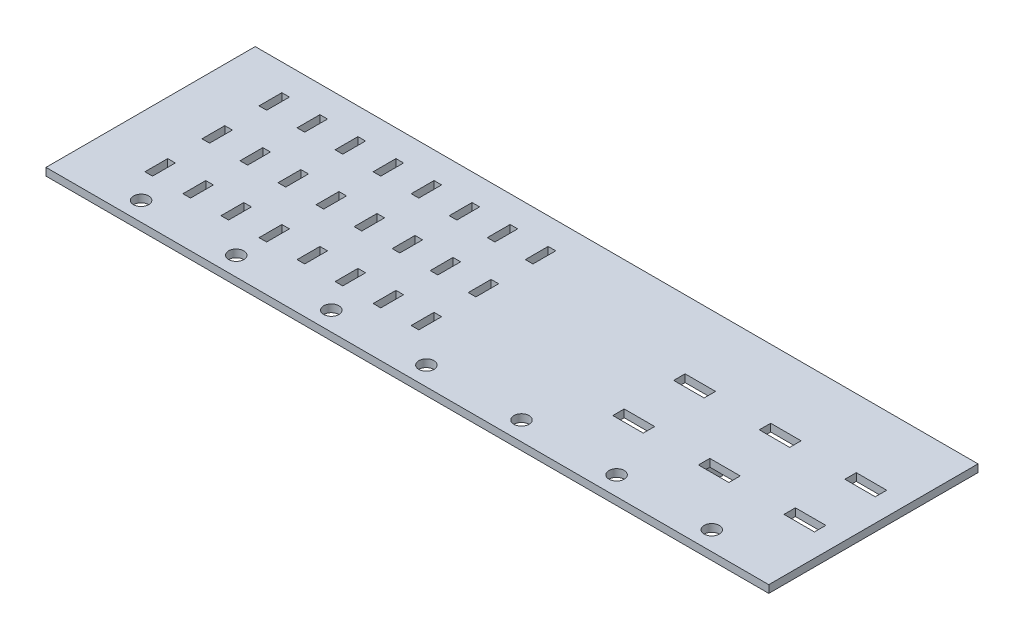
from build123d import *

# Parameters (mm, degrees)
SKETCH1_W                 = 190
SKETCH1_H                 = 55
SKETCH1_R                 = 2
BOSS_EXTRUDE1_DEPTH       = 2
SKETCH2_W                 = 10
SKETCH2_H                 = 10
BOSS_EXTRUDE2_DEPTH       = 7.1
LPATTERN1_COUNT           = 2
LPATTERN1_PITCH           = 22.5
SKETCH3_W                 = 8
SKETCH3_H                 = 3
CUT_EXTRUDE1_DEPTH        = 7.1
LPATTERN2_COUNT           = 3
LPATTERN2_PITCH           = 22.5
SKETCH4_W                 = 2
SKETCH4_H                 = 6
CUT_EXTRUDE2_DEPTH        = 7.1
LPATTERN3_COUNT           = 3
LPATTERN3_PITCH           = 15
LPATTERN4_COUNT           = 4
LPATTERN4_PITCH           = 20
LPATTERN4_COPY_1_SKETCH_W = 2
LPATTERN4_COPY_1_SKETCH_H = 6
LPATTERN4_COPY_1_DEPTH    = 7.1
LPATTERN4_COPY_2_SKETCH_W = 2
LPATTERN4_COPY_2_SKETCH_H = 6
LPATTERN4_COPY_2_DEPTH    = 7.1
LPATTERN4_COPY_3_SKETCH_W = 2
LPATTERN4_COPY_3_SKETCH_H = 6
LPATTERN4_COPY_3_DEPTH    = 7.1
LPATTERN4_COPY_4_SKETCH_W = 2
LPATTERN4_COPY_4_SKETCH_H = 6
LPATTERN4_COPY_4_DEPTH    = 7.1
LPATTERN4_COPY_5_SKETCH_W = 2
LPATTERN4_COPY_5_SKETCH_H = 6
LPATTERN4_COPY_5_DEPTH    = 7.1
LPATTERN4_COPY_6_SKETCH_W = 2
LPATTERN4_COPY_6_SKETCH_H = 6
LPATTERN4_COPY_6_DEPTH    = 7.1
SKETCH5_W                 = 10
SKETCH5_H                 = 10
BOSS_EXTRUDE3_DEPTH       = 7.1


with BuildPart() as part:
    # Sketch1 → Boss-Extrude1 (new body)
    with BuildSketch(Plane(origin=(0, 0, 0), x_dir=(1, 0, 0), z_dir=(0, 1, 0))):
        with Locations((75, 22.5)):
            Rectangle(SKETCH1_W, SKETCH1_H)
        Circle(SKETCH1_R, mode=Mode.SUBTRACT)
        with Locations((25, 0)):
            Circle(SKETCH1_R, mode=Mode.SUBTRACT)
        with Locations((50, 0)):
            Circle(SKETCH1_R, mode=Mode.SUBTRACT)
        with Locations((75, 0)):
            Circle(SKETCH1_R, mode=Mode.SUBTRACT)
        with Locations((100, 0)):
            Circle(SKETCH1_R, mode=Mode.SUBTRACT)
        with Locations((125, 0)):
            Circle(SKETCH1_R, mode=Mode.SUBTRACT)
        with Locations((150, 0)):
            Circle(SKETCH1_R, mode=Mode.SUBTRACT)
    extrude(amount=BOSS_EXTRUDE1_DEPTH)

    # Sketch2 → Boss-Extrude2 (add)
    with BuildSketch(Plane.XZ):
        with Locations((125, -22.5)):
            Rectangle(SKETCH2_W, SKETCH2_H)
    boss_extrude2 = extrude(amount=BOSS_EXTRUDE2_DEPTH)

    # LPattern1: Boss-Extrude2 ×2
    with Locations(*[(0, 0, -i * LPATTERN1_PITCH) for i in range(1, LPATTERN1_COUNT)]):
        add(boss_extrude2)

    # Sketch3 → Cut-Extrude1 (cut)
    with BuildSketch(Plane(origin=(0, 2, 0), x_dir=(1, 0, 0), z_dir=(0, 1, 0))):
        with Locations((160, 30.5)):
            Rectangle(SKETCH3_W, SKETCH3_H)
        with Locations((160, 14.5)):
            Rectangle(SKETCH3_W, SKETCH3_H)
    cut_extrude1 = extrude(amount=-CUT_EXTRUDE1_DEPTH, mode=Mode.SUBTRACT)

    # LPattern2: Cut-Extrude1 ×3
    with Locations(*[(-i * LPATTERN2_PITCH, 0, 0) for i in range(1, LPATTERN2_COUNT)]):
        add(cut_extrude1, mode=Mode.SUBTRACT)

    # Sketch4 → Cut-Extrude2 (cut)
    with BuildSketch(Plane(origin=(0, 2, 0), x_dir=(1, 0, 0), z_dir=(0, 1, 0))):
        with Locations((-5, 10)):
            Rectangle(SKETCH4_W, SKETCH4_H)
        with Locations((5, 10)):
            Rectangle(SKETCH4_W, SKETCH4_H)
    cut_extrude2 = extrude(amount=-CUT_EXTRUDE2_DEPTH, mode=Mode.SUBTRACT)

    # LPattern3: Cut-Extrude2 ×3
    with Locations(*[(0, 0, -i * LPATTERN3_PITCH) for i in range(1, LPATTERN3_COUNT)]):
        add(cut_extrude2, mode=Mode.SUBTRACT)

    # LPattern4: Cut-Extrude2 ×4
    with Locations(*[(i * LPATTERN4_PITCH, 0, 0) for i in range(1, LPATTERN4_COUNT)]):
        add(cut_extrude2, mode=Mode.SUBTRACT)

    # LPattern4 copy 1 sketch → LPattern4 copy 1 (cut)
    with BuildSketch(Plane(origin=(20, 2, -15), x_dir=(1, 0, 0), z_dir=(0, 1, 0))):
        with Locations((-5, 10)):
            Rectangle(LPATTERN4_COPY_1_SKETCH_W, LPATTERN4_COPY_1_SKETCH_H)
        with Locations((5, 10)):
            Rectangle(LPATTERN4_COPY_1_SKETCH_W, LPATTERN4_COPY_1_SKETCH_H)
    extrude(amount=-LPATTERN4_COPY_1_DEPTH, mode=Mode.SUBTRACT)

    # LPattern4 copy 2 sketch → LPattern4 copy 2 (cut)
    with BuildSketch(Plane(origin=(40, 2, -15), x_dir=(1, 0, 0), z_dir=(0, 1, 0))):
        with Locations((-5, 10)):
            Rectangle(LPATTERN4_COPY_2_SKETCH_W, LPATTERN4_COPY_2_SKETCH_H)
        with Locations((5, 10)):
            Rectangle(LPATTERN4_COPY_2_SKETCH_W, LPATTERN4_COPY_2_SKETCH_H)
    extrude(amount=-LPATTERN4_COPY_2_DEPTH, mode=Mode.SUBTRACT)

    # LPattern4 copy 3 sketch → LPattern4 copy 3 (cut)
    with BuildSketch(Plane(origin=(60, 2, -15), x_dir=(1, 0, 0), z_dir=(0, 1, 0))):
        with Locations((-5, 10)):
            Rectangle(LPATTERN4_COPY_3_SKETCH_W, LPATTERN4_COPY_3_SKETCH_H)
        with Locations((5, 10)):
            Rectangle(LPATTERN4_COPY_3_SKETCH_W, LPATTERN4_COPY_3_SKETCH_H)
    extrude(amount=-LPATTERN4_COPY_3_DEPTH, mode=Mode.SUBTRACT)

    # LPattern4 copy 4 sketch → LPattern4 copy 4 (cut)
    with BuildSketch(Plane(origin=(20, 2, -30), x_dir=(1, 0, 0), z_dir=(0, 1, 0))):
        with Locations((-5, 10)):
            Rectangle(LPATTERN4_COPY_4_SKETCH_W, LPATTERN4_COPY_4_SKETCH_H)
        with Locations((5, 10)):
            Rectangle(LPATTERN4_COPY_4_SKETCH_W, LPATTERN4_COPY_4_SKETCH_H)
    extrude(amount=-LPATTERN4_COPY_4_DEPTH, mode=Mode.SUBTRACT)

    # LPattern4 copy 5 sketch → LPattern4 copy 5 (cut)
    with BuildSketch(Plane(origin=(40, 2, -30), x_dir=(1, 0, 0), z_dir=(0, 1, 0))):
        with Locations((-5, 10)):
            Rectangle(LPATTERN4_COPY_5_SKETCH_W, LPATTERN4_COPY_5_SKETCH_H)
        with Locations((5, 10)):
            Rectangle(LPATTERN4_COPY_5_SKETCH_W, LPATTERN4_COPY_5_SKETCH_H)
    extrude(amount=-LPATTERN4_COPY_5_DEPTH, mode=Mode.SUBTRACT)

    # LPattern4 copy 6 sketch → LPattern4 copy 6 (cut)
    with BuildSketch(Plane(origin=(60, 2, -30), x_dir=(1, 0, 0), z_dir=(0, 1, 0))):
        with Locations((-5, 10)):
            Rectangle(LPATTERN4_COPY_6_SKETCH_W, LPATTERN4_COPY_6_SKETCH_H)
        with Locations((5, 10)):
            Rectangle(LPATTERN4_COPY_6_SKETCH_W, LPATTERN4_COPY_6_SKETCH_H)
    extrude(amount=-LPATTERN4_COPY_6_DEPTH, mode=Mode.SUBTRACT)

    # Sketch5 → Boss-Extrude3 (add)
    with BuildSketch(Plane.XZ):
        with Locations((-15, -45)):
            Rectangle(SKETCH5_W, SKETCH5_H)
        with Locations((-15, -20)):
            Rectangle(SKETCH5_W, SKETCH5_H)
    extrude(amount=BOSS_EXTRUDE3_DEPTH)


solid = part.part
